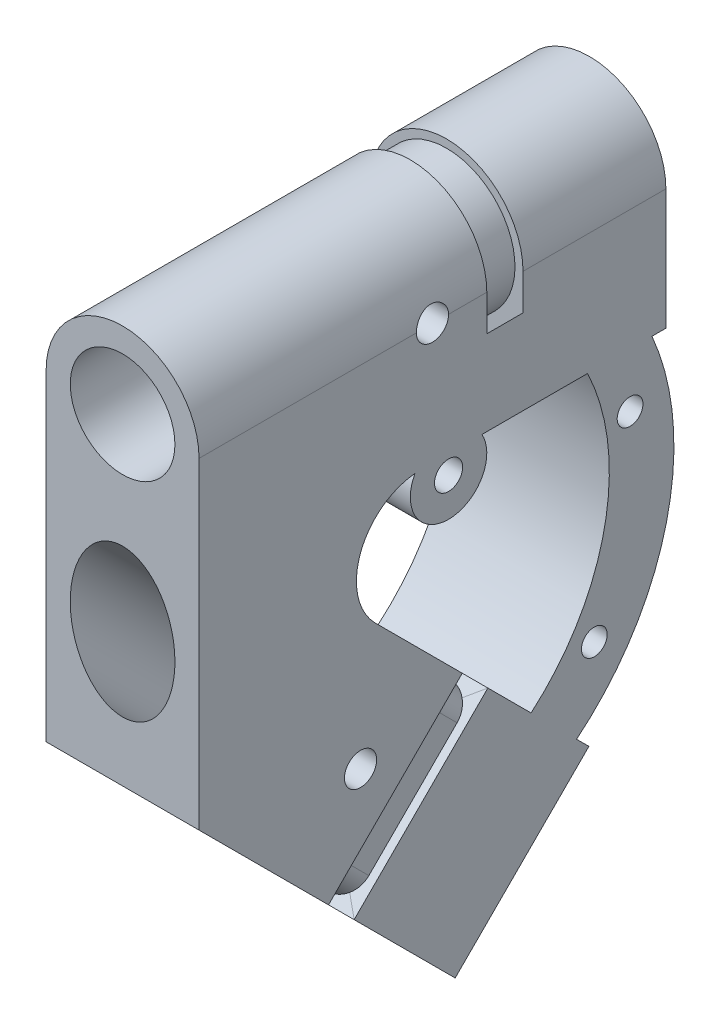
from build123d import *

# Parameters (mm, degrees)
CROQUIS1_R                   = 6.5
SALIENTE_EXTRUIR1_DEPTH      = 29
SALIENTE_EXTRUIR2_DEPTH      = 9.5
SALIENTE_EXTRUIR2_DEPTH_BACK = 9.5
CROQUIS4_R                   = 6.5
CORTAR_EXTRUIR1_DEPTH        = 80
SALIENTE_EXTRUIR3_START      = -9.5
SALIENTE_EXTRUIR3_DEPTH      = 19
SALIENTE_EXTRUIR4_START      = -9.5
CROQUIS8_R                   = 4.75
CROQUIS8_R_2                 = 1.75
SALIENTE_EXTRUIR4_DEPTH      = 19
CROQUIS9_R                   = 1.6
CORTAR_EXTRUIR2_DEPTH        = 10.5
CROQUIS10_R                  = 2
CORTAR_EXTRUIR3_DEPTH        = 20
REDONDEO1_R                  = 3
CROQUIS13_W                  = 4.5
CROQUIS13_H                  = 2


with BuildPart() as part:
    # Croquis1 → Saliente-Extruir1 (new body, symmetric)
    with BuildSketch(Plane.XY):
        with BuildLine():
            Line((-9.5, -15), (9.5, -15))
            Line((9.5, -15), (9.5, 0))
            ThreePointArc((9.5, 0), (0, 9.5), (-9.5, 0))
            Line((-9.5, 0), (-9.5, -15))
        make_face()
        Circle(CROQUIS1_R, mode=Mode.SUBTRACT)
    extrude(amount=SALIENTE_EXTRUIR1_DEPTH, both=True)

    # Croquis2 → Saliente-Extruir2 (add, two sides)
    with BuildSketch(Plane(origin=(0, 0, 0), x_dir=(0, 0, -1), z_dir=(1, 0, 0))) as saliente_extruir2_sk:
        with BuildLine():
            Line((-29, -15), (-29, -40))
            Line((-29, -40), (2.819805153, -71.819805153))
            Line((2.819805153, -71.819805153), (19.436814511, -55.202795796))
            Line((19.436814511, -55.202795796), (-7.109127035, -28.656854249))
            ThreePointArc((-7.109127035, -28.656854249), (-8.843309045, -19.938532541), (-1.452272785, -15))
            Line((-1.452272785, -15), (-29, -15))
        make_face()
    extrude(amount=SALIENTE_EXTRUIR2_DEPTH)
    extrude(saliente_extruir2_sk.sketch, amount=-SALIENTE_EXTRUIR2_DEPTH_BACK)

    # Croquis4 → Cortar-Extruir1 (cut)
    with BuildSketch(Plane(origin=(0, -37.319805153, -37.319805153), x_dir=(-1, 0, 0), z_dir=(0, -0.707106781, -0.707106781))):
        with Locations((0, -37.040367902)):
            Circle(CROQUIS4_R)
    extrude(amount=-CORTAR_EXTRUIR1_DEPTH, mode=Mode.SUBTRACT)

    # Croquis7 → Saliente-Extruir3 (add)
    with BuildSketch(Plane(origin=(0, 0, 0), x_dir=(0, 0, -1), z_dir=(1, 0, 0)).offset(SALIENTE_EXTRUIR3_START)):
        with BuildLine():
            Line((19.27018783, -15), (27.27018783, -15))
            ThreePointArc((27.27018783, -15), (29.073531932, -35.90670576), (17.9077889, -53.673770184))
            Line((17.9077889, -53.673770184), (12.25093465, -48.016915935))
            ThreePointArc((12.25093465, -48.016915935), (21.365831267, -32.700114073), (19.27018783, -15))
        make_face()
    extrude(amount=SALIENTE_EXTRUIR3_DEPTH)

    # Croquis8 → Saliente-Extruir4 (add)
    with BuildSketch(Plane(origin=(0, 0, 0), x_dir=(0, 0, -1), z_dir=(1, 0, 0)).offset(SALIENTE_EXTRUIR4_START)):
        with Locations((2, -17.311351178)):
            Circle(CROQUIS8_R)
        with Locations((2, -17.311351178)):
            Circle(CROQUIS8_R_2, mode=Mode.SUBTRACT)
    extrude(amount=SALIENTE_EXTRUIR4_DEPTH)

    # Croquis9 → Cortar-Extruir2 (cut, symmetric)
    with BuildSketch(Plane(origin=(0, 0, 0), x_dir=(0, 0, -1), z_dir=(1, 0, 0))):
        with Locations((24.550935782, -21.731271468)):
            Circle(CROQUIS9_R)
        with Locations((20.109439567, -44.298351726)):
            Circle(CROQUIS9_R)
    extrude(amount=CORTAR_EXTRUIR2_DEPTH, both=True, mode=Mode.SUBTRACT)

    # Croquis10 → Cortar-Extruir3 (cut, symmetric)
    with BuildSketch(Plane(origin=(0, 0, 0), x_dir=(0, 0, -1), z_dir=(1, 0, 0))):
        Circle(CROQUIS10_R)
        with Locations((-8.935845084, -43.447145558)):
            Circle(CROQUIS10_R)
    extrude(amount=CORTAR_EXTRUIR3_DEPTH, both=True, mode=Mode.SUBTRACT)

    # Cortar-Barrer1: sweep along a path in Croquis11
    with BuildLine(Plane(origin=(0, -23.17766953, -23.17766953), x_dir=(-1, 0, 0), z_dir=(0, -0.707106781, -0.707106781))) as cortar_barrer1_path:
        Line((-9.5, -48.790367902), (-9.5, -25.290367902))
        Line((-9.5, -25.290367902), (9.5, -25.290367902))
        Line((9.5, -25.290367902), (9.5, -48.790367902))
        Line((9.5, -48.790367902), (-9.5, -48.790367902))
    # Croquis12 → Cortar-Barrer1 (sweep, cut)
    with BuildSketch(Plane.ZY.offset(9.5)):
        Polygon((-3.70368863, -39.469669914), (-6.885669145, -42.651650429), (-6.178562364, -43.358757211), (-2.996581849, -40.176776695), align=None)
    sweep(path=cortar_barrer1_path.line, transition=Transition.RIGHT, mode=Mode.SUBTRACT)

    # Redondeo1
    redondeo1_edges = [part.edges().sort_by_distance(p)[0] for p in [
        (8.5, -56.970562748, 10.615223689),
        (-8.5, -56.970562748, 10.615223689),
        (8.5, -41.767766953, -4.587572106),
        (-8.5, -41.767766953, -4.587572106),
    ]]
    fillet(redondeo1_edges, radius=REDONDEO1_R)

    # Cortar-Barrer3: sweep along a path in Croquis14
    with BuildLine(Plane(origin=(0, 0, -9), x_dir=(-1, 0, 0), z_dir=(0, 0, -1))) as cortar_barrer3_path:
        CenterArc((0, 0), 9.5, 0, 360)
    # Croquis13 → Cortar-Barrer3 (sweep, cut)
    with BuildSketch(Plane(origin=(0, 0, 0), x_dir=(0, 0, -1), z_dir=(1, 0, 0))):
        with Locations((9, 9.5)):
            Rectangle(CROQUIS13_W, CROQUIS13_H)
    sweep(path=cortar_barrer3_path.line, mode=Mode.SUBTRACT)


solid = part.part
